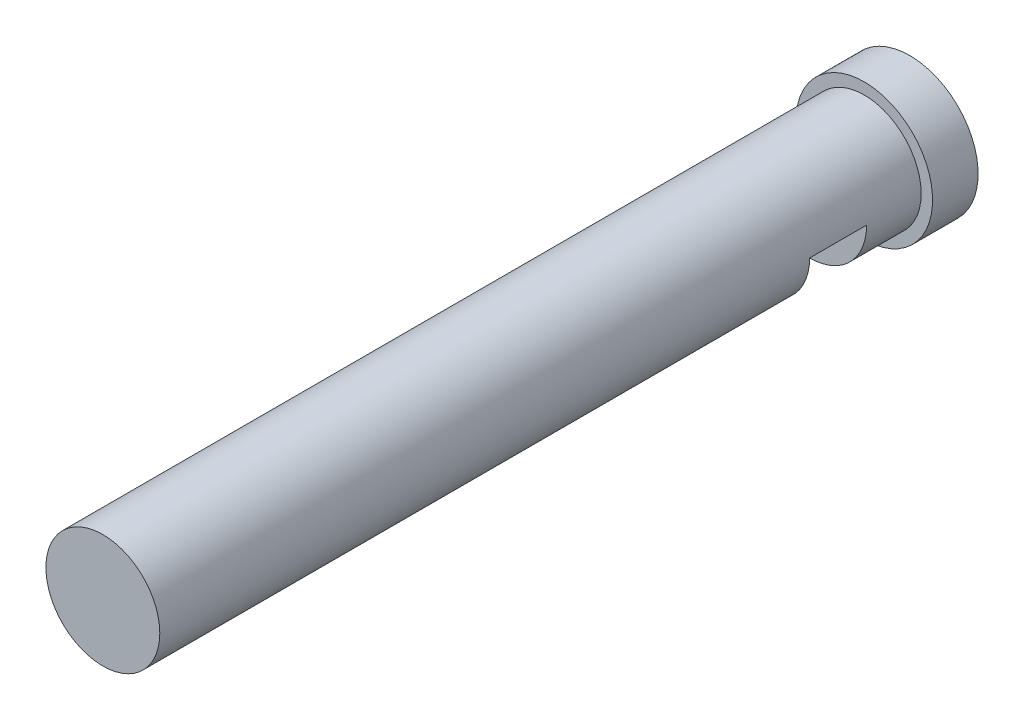
from build123d import *

# Parameters (mm, degrees)
SKETCH1_R           = 6.35
BOSS_EXTRUDE1_DEPTH = 6.0833
SKETCH4_R           = 7.62
BOSS_EXTRUDE2_DEPTH = 5.08
BOSS_EXTRUDE3_DEPTH = 6.35
SKETCH13_R          = 6.35
BOSS_EXTRUDE4_DEPTH = 72.46112


with BuildPart() as part:
    # Sketch1 → Boss-Extrude1 (new body)
    with BuildSketch(Plane.XY):
        Circle(SKETCH1_R)
    extrude(amount=BOSS_EXTRUDE1_DEPTH)

    # Sketch4 → Boss-Extrude2 (add)
    with BuildSketch(Plane(origin=(0, 0, 0), x_dir=(-1, 0, 0), z_dir=(0, 0, -1))):
        Circle(SKETCH4_R)
    extrude(amount=BOSS_EXTRUDE2_DEPTH)

    # Sketch12 → Boss-Extrude3 (add)
    with BuildSketch(Plane.XY.offset(6.0833)):
        with BuildLine():
            Line((0, -6.35), (6.35, 0))
            ThreePointArc((6.35, 0), (-4.490128061, 4.490128061), (0, -6.35))
        make_face()
    extrude(amount=BOSS_EXTRUDE3_DEPTH)

    # Sketch13 → Boss-Extrude4 (add)
    with BuildSketch(Plane.XY.offset(12.4333)):
        Circle(SKETCH13_R)
    extrude(amount=BOSS_EXTRUDE4_DEPTH)


solid = part.part
